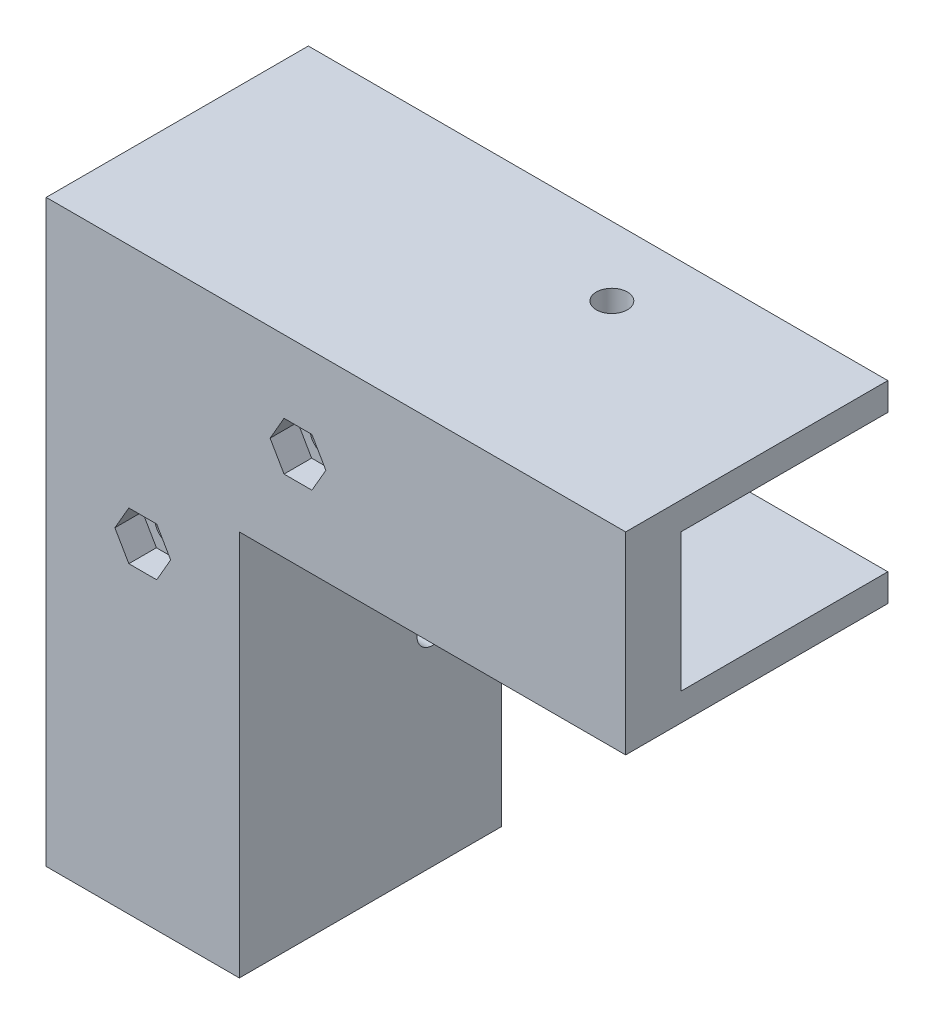
from build123d import *

# Parameters (mm, degrees)
BOSS_EXTRU_1_DEPTH      = 8
ENL_V_MAT_EXTRU_1_DEPTH = 4
ESQUISSE3_R             = 2.25
ENL_V_MAT_EXTRU_2_DEPTH = 5
BOSS_EXTRU_2_DEPTH      = 38
ESQUISSE5_R             = 2.25
ENL_V_MAT_EXTRU_3_DEPTH = 29
ESQUISSE6_R             = 2.25
ENL_V_MAT_EXTRU_4_DEPTH = 29
CONG_1_R                = 6


with BuildPart() as part:
    # Esquisse1 → Boss.-Extru.1 (new body)
    with BuildSketch(Plane.XY):
        Polygon((0, 0), (0, 60), (60, 60), (60, 80), (-20, 80), (-20, 0), align=None)
    extrude(amount=BOSS_EXTRU_1_DEPTH)

    # Esquisse2 → Enlèv. mat.-Extru.1 (cut)
    with BuildSketch(Plane.XY.offset(8)):
        Polygon((-14.041451884, 47.5), (-12.020725942, 51), (-7.979274058, 51), (-5.958548116, 47.5), (-7.979274058, 44), (-12.020725942, 44), align=None)
        Polygon((8.458548116, 70), (10.479274058, 73.5), (14.520725942, 73.5), (16.541451884, 70), (14.520725942, 66.5), (10.479274058, 66.5), align=None)
    extrude(amount=-ENL_V_MAT_EXTRU_1_DEPTH, mode=Mode.SUBTRACT)

    # Esquisse3 → Enlèv. mat.-Extru.2 (cut, through all)
    with BuildSketch(Plane.XY.offset(4)):
        with Locations((-10, 47.5)):
            Circle(ESQUISSE3_R)
        with Locations((12.5, 70)):
            Circle(ESQUISSE3_R)
    extrude(amount=-ENL_V_MAT_EXTRU_2_DEPTH, mode=Mode.SUBTRACT)

    # Esquisse4 → Boss.-Extru.2 (add)
    with BuildSketch(Plane.XY.offset(8)):
        Polygon((0, 0), (0, 60), (60, 60), (60, 56), (4, 56), (4, 0), align=None)
        Polygon((60, 80), (60, 84), (-24, 84), (-24, 0), (-20, 0), (-20, 80), align=None)
    extrude(amount=-BOSS_EXTRU_2_DEPTH)

    # Esquisse5 → Enlèv. mat.-Extru.3 (cut, through all)
    with BuildSketch(Plane.XZ.offset(-56)):
        with Locations((30, -20)):
            Circle(ESQUISSE5_R)
    extrude(amount=-ENL_V_MAT_EXTRU_3_DEPTH, mode=Mode.SUBTRACT)

    # Esquisse6 → Enlèv. mat.-Extru.4 (cut, through all)
    with BuildSketch(Plane(origin=(4, 0, 0), x_dir=(0, 0, -1), z_dir=(1, 0, 0))):
        with Locations(Location((20, 30, 0), (0, 0, 90))):  # turned: the seam where the file's is
            Circle(ESQUISSE6_R)
    extrude(amount=-ENL_V_MAT_EXTRU_4_DEPTH, mode=Mode.SUBTRACT)

    # Congé1
    cong_1_edges = [part.edges().sort_by_distance(p)[0] for p in [
        (0, 60, -15),
    ]]
    fillet(cong_1_edges, radius=CONG_1_R)


solid = part.part
